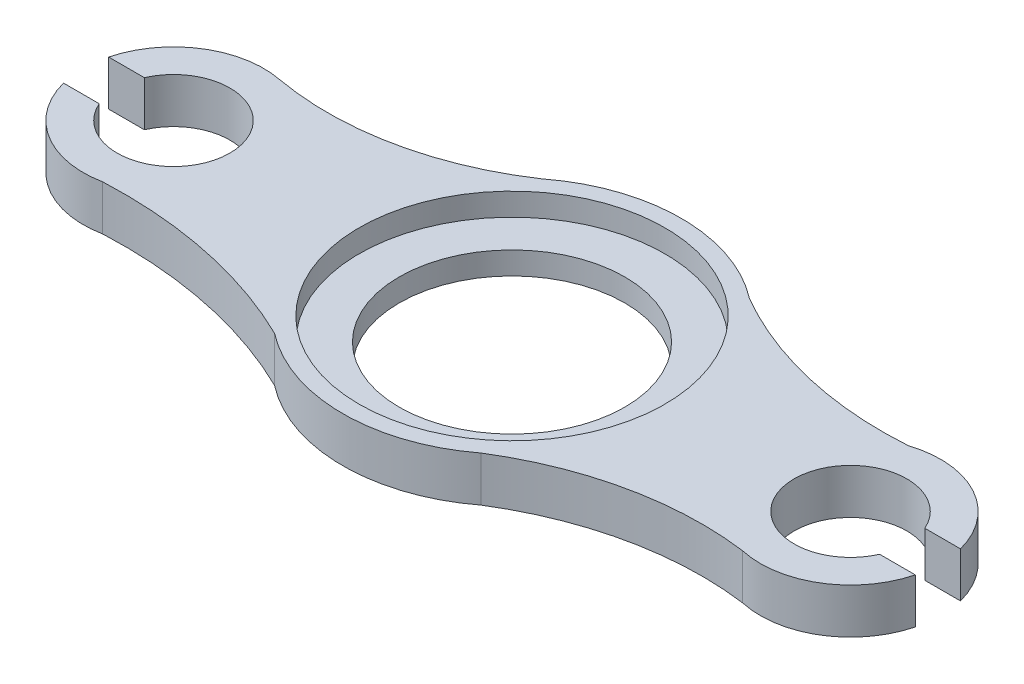
from build123d import *

# Parameters (mm, degrees)
ESQUISSE1_W             = 380
ESQUISSE1_H             = 150
BOSS_EXTRU_1_DEPTH      = 20
ESQUISSE2_R             = 50
ESQUISSE2_W             = 36.086047363
ESQUISSE2_H             = 20
ENL_V_MAT_EXTRU_2_DEPTH = 21
ESQUISSE4_R             = 67.75
ENL_V_MAT_EXTRU_3_DEPTH = 10
ENL_V_MAT_EXTRU_4_DEPTH = 21


with BuildPart() as part:
    # Esquisse1 → Boss.-Extru.1 (new body)
    with BuildSketch(Plane(origin=(0, 0, 0), x_dir=(1, 0, 0), z_dir=(0, 1, 0))):
        Rectangle(ESQUISSE1_W, ESQUISSE1_H)
    extrude(amount=BOSS_EXTRU_1_DEPTH)

    # Esquisse2 → Enlèv. mat.-Extru.2 (cut, through all)
    with BuildSketch(Plane(origin=(0, 0, 0), x_dir=(-1, 0, 0), z_dir=(0, -1, 0))):
        with BuildLine():
            Line((172.912878475, -10), (190, -10))
            Line((190, -10), (190, 10))
            Line((190, 10), (172.912878475, 10))
            ThreePointArc((172.912878475, 10), (174.472657823, 5.107741092), (175, 0))
            ThreePointArc((175, 0), (174.472657823, -5.107741092), (172.912878475, -10))
        make_face()
        with BuildLine():
            ThreePointArc((172.912878475, 10), (125, 0), (172.912878475, -10))
            Line((172.912878475, -10), (159.255580532, -10))
            Line((159.255580532, -10), (159.255580532, 10))
            Line((159.255580532, 10), (172.912878475, 10))
        make_face()
        with BuildLine():
            Line((159.255580532, -10), (172.912878475, -10))
            ThreePointArc((172.912878475, -10), (174.472657823, -5.107741092), (175, 0))
            ThreePointArc((175, 0), (174.472657823, 5.107741092), (172.912878475, 10))
            Line((172.912878475, 10), (159.255580532, 10))
            Line((159.255580532, 10), (159.255580532, -10))
        make_face()
        Circle(ESQUISSE2_R)
        with BuildLine():
            Line((-154.989806054, 10), (-154.989806054, -10))
            Line((-154.989806054, -10), (-172.912878475, -10))
            ThreePointArc((-172.912878475, -10), (-144.892258908, -24.472657823), (-125, 0))
            ThreePointArc((-125, 0), (-144.892258908, 24.472657823), (-172.912878475, 10))
            Line((-172.912878475, 10), (-154.989806054, 10))
        make_face()
        with BuildLine():
            Line((-172.912878475, -10), (-154.989806054, -10))
            Line((-154.989806054, -10), (-154.989806054, 10))
            Line((-154.989806054, 10), (-172.912878475, 10))
            ThreePointArc((-172.912878475, 10), (-175, 0), (-172.912878475, -10))
        make_face()
        with Locations((-208.043023682, 0)):
            Rectangle(ESQUISSE2_W, ESQUISSE2_H)
        with BuildLine():
            Line((-190, -10), (-172.912878475, -10))
            ThreePointArc((-172.912878475, -10), (-175, 0), (-172.912878475, 10))
            Line((-172.912878475, 10), (-190, 10))
            Line((-190, 10), (-190, -10))
        make_face()
    extrude(amount=-ENL_V_MAT_EXTRU_2_DEPTH, mode=Mode.SUBTRACT)

    # Esquisse4 → Enlèv. mat.-Extru.3 (cut)
    with BuildSketch(Plane(origin=(0, 20, 0), x_dir=(1, 0, 0), z_dir=(0, 1, 0))):
        Circle(ESQUISSE4_R)
    extrude(amount=-ENL_V_MAT_EXTRU_3_DEPTH, mode=Mode.SUBTRACT)

    # Esquisse5 → Enlèv. mat.-Extru.4 (cut, through all)
    with BuildSketch(Plane(origin=(0, 20, 0), x_dir=(1, 0, 0), z_dir=(0, 1, 0))):
        with BuildLine():
            ThreePointArc((-45.987048839, -59.246867758), (-92.825023805, -43.159932782), (-142.192482618, -39.230634361))
            ThreePointArc((-142.192482618, -39.230634361), (-171.275688102, -33.87248287), (-188.729833462, -10))
            Line((-188.729833462, -10), (-190, -10))
            Line((-190, -10), (-190, -75))
            Line((-190, -75), (-6.82e-07, -75))
            ThreePointArc((-6.82e-07, -75), (-24.305194399, -70.952501896), (-45.987048839, -59.246867758))
        make_face()
        with BuildLine():
            ThreePointArc((-188.729833462, 10), (-171.275688102, 33.87248287), (-142.192482618, 39.230634361))
            ThreePointArc((-142.192482618, 39.230634361), (-92.140738349, 39.871003351), (-45.987048839, 59.246867758))
            ThreePointArc((-45.987048839, 59.246867758), (-24.305194053, 70.952502014), (4.9e-08, 75))
            Line((4.9e-08, 75), (-190, 75))
            Line((-190, 75), (-190, 10))
            Line((-190, 10), (-188.729833462, 10))
        make_face()
        with BuildLine():
            Line((190, 75), (4.9e-08, 75))
            ThreePointArc((4.9e-08, 75), (24.3051941, 70.952501998), (45.987048839, 59.246867758))
            ThreePointArc((45.987048839, 59.246867758), (90.245637387, 41.772491768), (137.68369163, 38.056649198))
            ThreePointArc((137.68369163, 38.056649198), (169.266874889, 35.054065841), (188.729833462, 10))
            Line((188.729833462, 10), (190, 10))
            Line((190, 10), (190, 75))
        make_face()
        with BuildLine():
            ThreePointArc((45.671882044, -59.490160452), (24.116777718, -71.016765855), (-6.82e-07, -75))
            Line((-6.82e-07, -75), (190, -75))
            Line((190, -75), (190, -10))
            Line((190, -10), (188.729833462, -10))
            ThreePointArc((188.729833462, -10), (170.810992049, -34.159956234), (141.123685996, -39.002705671))
            ThreePointArc((141.123685996, -39.002705671), (91.61350334, -40.933403872), (45.671882044, -59.490160452))
        make_face()
    extrude(amount=-ENL_V_MAT_EXTRU_4_DEPTH, mode=Mode.SUBTRACT)


solid = part.part
